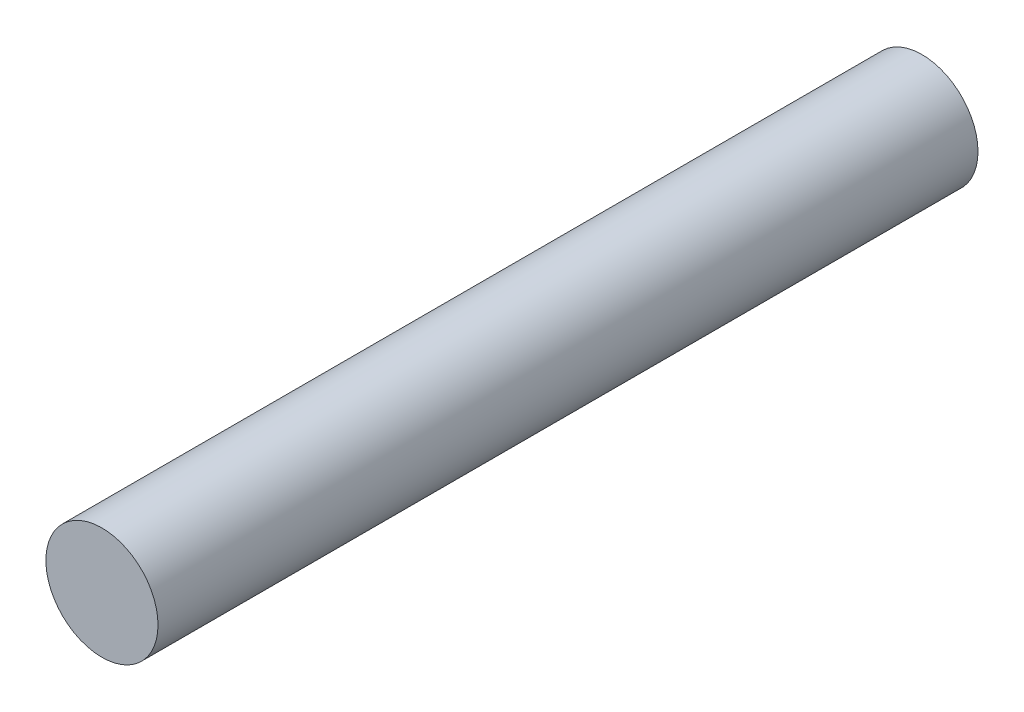
from build123d import *

# Parameters (mm, degrees)
SKETCH1_R           = 2.3876
BOSS_EXTRUDE1_DEPTH = 17.4625


with BuildPart() as part:
    # Sketch1 → Boss-Extrude1 (new body, symmetric)
    with BuildSketch(Plane.XY):
        Circle(SKETCH1_R)
    extrude(amount=BOSS_EXTRUDE1_DEPTH, both=True)


solid = part.part
